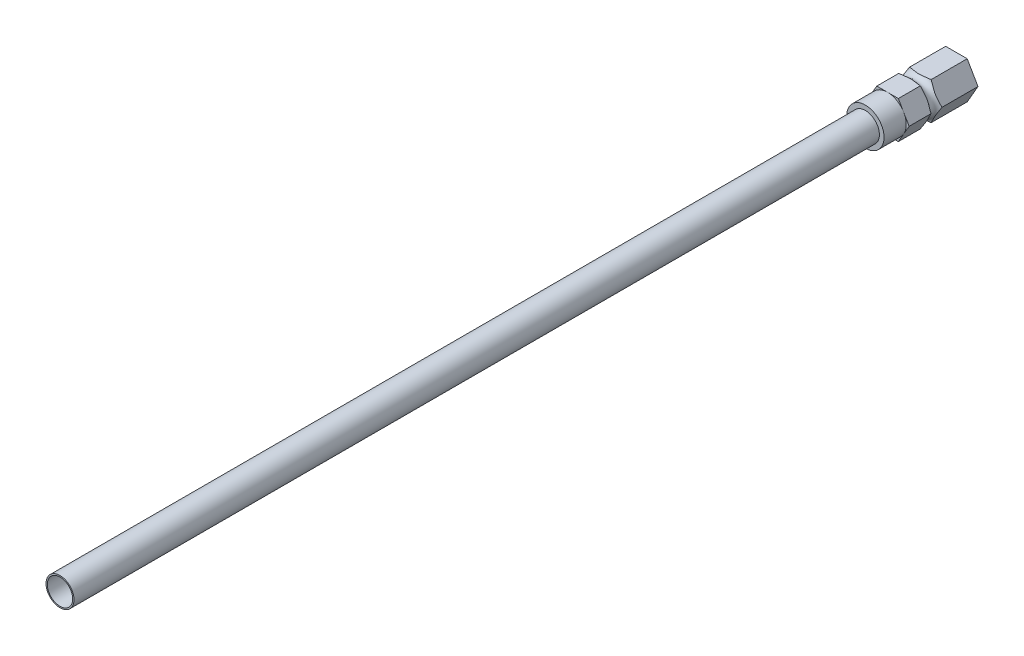
from build123d import *

# Parameters (mm, degrees)
SKETCH1_R           = 9.525
SKETCH1_R_2         = 8.636
BOSS_EXTRUDE1_DEPTH = 609.6
SKETCH3_R           = 20.246819027
CUT_EXTRUDE1_DEPTH  = 101.6


with BuildPart() as part:
    # Sketch1 → Boss-Extrude1 (new body)
    with BuildSketch(Plane.XY):
        Circle(SKETCH1_R)
        Circle(SKETCH1_R_2, mode=Mode.SUBTRACT)
    extrude(amount=BOSS_EXTRUDE1_DEPTH)

    # Sketch2 → Revolve1 (revolve)
    with BuildSketch(Plane(origin=(0, 0, 0), x_dir=(0, 0, -1), z_dir=(1, 0, 0))):
        with BuildLine():
            Line((-61.9125, 9.525), (0, 9.525))
            Line((0, 9.525), (0, 17.78))
            Line((0, 17.78), (-25.722714052, 17.78))
            ThreePointArc((-25.722714052, 17.78), (-24.855324241, 16.552662429), (-24.549271858, 15.08125))
            ThreePointArc((-24.549271858, 15.08125), (-29.710775793, 11.697210877), (-30.756012676, 17.78))
            Line((-30.756012676, 17.78), (-46.83125, 17.78))
            Line((-46.83125, 17.78), (-46.83125, 12.7))
            Line((-46.83125, 12.7), (-61.9125, 12.7))
            Line((-61.9125, 12.7), (-61.9125, 9.525))
        make_face()
    revolve(axis=Axis((0, 0, 0), (0, 0, 1)))

    # Sketch3 → Cut-Extrude1 (cut)
    with BuildSketch(Plane(origin=(0, 0, 0), x_dir=(-1, 0, 0), z_dir=(0, 0, -1))):
        Circle(SKETCH3_R)
        Polygon((14.664696837, 0), (7.332348419, 12.7), (-7.332348419, 12.7), (-14.664696837, 0), (-7.332348419, -12.7), (7.332348419, -12.7), align=None, mode=Mode.SUBTRACT)
    extrude(amount=-CUT_EXTRUDE1_DEPTH, mode=Mode.SUBTRACT)


solid = part.part
